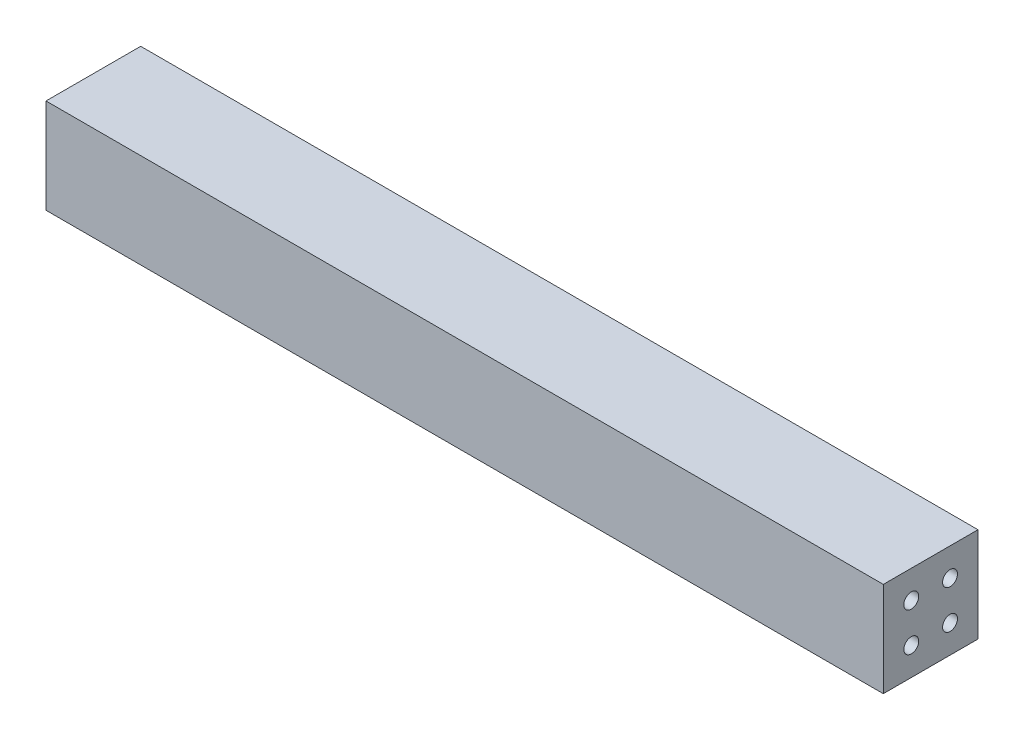
from build123d import *

# Parameters (mm, degrees)
CROQUIS1_W              = 449.2
CROQUIS1_H              = 50.8
SALIENTE_EXTRUIR1_DEPTH = 50.8
CROQUIS2_R              = 4
CORTAR_EXTRUIR1_DEPTH   = 10
CROQUIS3_R              = 4
CORTAR_EXTRUIR2_DEPTH   = 10


with BuildPart() as part:
    # Croquis1 → Saliente-Extruir1 (new body)
    with BuildSketch(Plane(origin=(0, 0, 0), x_dir=(1, 0, 0), z_dir=(0, 1, 0))):
        Rectangle(CROQUIS1_W, CROQUIS1_H)
    extrude(amount=SALIENTE_EXTRUIR1_DEPTH)

    # Croquis2 → Cortar-Extruir1 (cut)
    with BuildSketch(Plane(origin=(224.6, 0, 0), x_dir=(0, 0, -1), z_dir=(1, 0, 0))):
        with Locations((-10.4, 35.8)):
            Circle(CROQUIS2_R)
        with Locations((10.4, 35.8)):
            Circle(CROQUIS2_R)
        with Locations((10.4, 15)):
            Circle(CROQUIS2_R)
        with Locations((-10.4, 15)):
            Circle(CROQUIS2_R)
    extrude(amount=-CORTAR_EXTRUIR1_DEPTH, mode=Mode.SUBTRACT)

    # Croquis3 → Cortar-Extruir2 (cut)
    with BuildSketch(Plane.ZY.offset(224.6)):
        with Locations((10.4, 35.8)):
            Circle(CROQUIS3_R)
        with Locations((-10.4, 35.8)):
            Circle(CROQUIS3_R)
        with Locations((-10.4, 15)):
            Circle(CROQUIS3_R)
        with Locations((10.4, 15)):
            Circle(CROQUIS3_R)
    extrude(amount=-CORTAR_EXTRUIR2_DEPTH, mode=Mode.SUBTRACT)


solid = part.part
